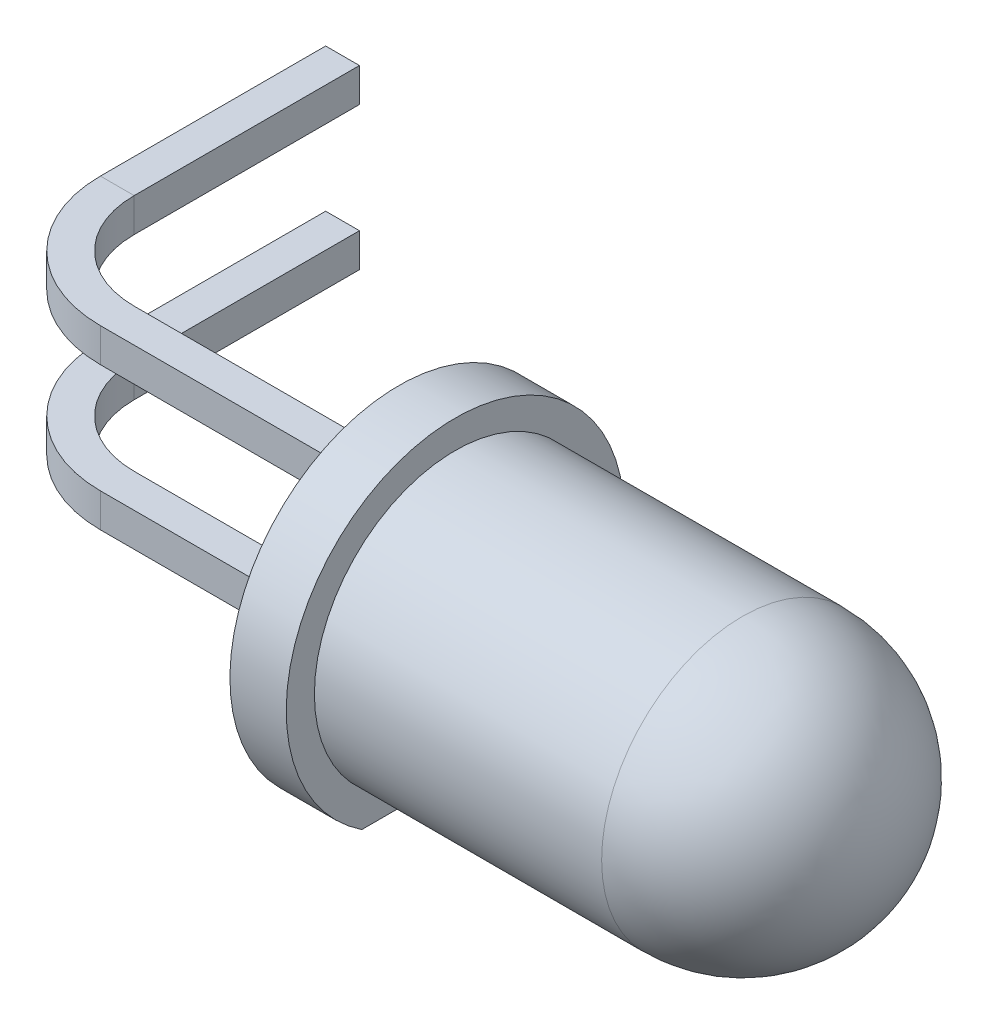
from build123d import *

# Parameters (mm, degrees)
ESQUISSE2_W             = 4.921723832
ESQUISSE2_H             = 0.78450296
ENL_V_MAT_EXTRU_1_DEPTH = 9.6
ESQUISSE3_W             = 0.6
ESQUISSE3_H             = 0.6
BOSS_EXTRU_2_DEPTH      = 5
BOSS_EXTRU_2_DEPTH_BACK = 5
BOSS_EXTRU_3_DEPTH      = 0.6
BOSS_EXTRU_4_DEPTH      = 0.6
ESQUISSE5_W             = 0.6
ESQUISSE5_H             = 0.6


with BuildPart() as part:
    # Esquisse1 → Révolution1 (revolve)
    with BuildSketch(Plane.XY, mode=Mode.PRIVATE) as r_volution1_sk:
        with BuildLine():
            Line((0, 0), (0, 3))
            Line((0, 3), (1, 3))
            Line((1, 3), (1, 2.5))
            Line((1, 2.5), (6.1, 2.5))
            ThreePointArc((6.1, 2.5), (7.867766953, 1.767766953), (8.6, 0))
            Line((8.6, 0), (8.55, 0))
            ThreePointArc((8.55, 0), (7.832411614, 1.732411614), (6.1, 2.45))
            Line((6.1, 2.45), (0.95, 2.45))
            Line((0.95, 2.45), (0.95, 2.95))
            Line((0.95, 2.95), (0.05, 2.95))
            Line((0.05, 2.95), (0.05, 0))
            Line((0.05, 0), (0, 0))
        make_face()
    revolve(r_volution1_sk.sketch.rotate(Axis((-3.652103808, 0, 0), (1, 0, 0)), 90), axis=Axis((-3.652103808, 0, 0), (1, 0, 0)))  # turned: the seam where the file's is

    # Esquisse2 → Enlèv. mat.-Extru.1 (cut, through all)
    with BuildSketch(Plane.ZY):
        with Locations((0.14038474, -2.89225148)):
            Rectangle(ESQUISSE2_W, ESQUISSE2_H)
    extrude(amount=-ENL_V_MAT_EXTRU_1_DEPTH, mode=Mode.SUBTRACT)

    # Esquisse3 → Boss.-Extru.2 (add, two sides)
    with BuildSketch(Plane.ZY) as boss_extru_2_sk:
        with Locations((0, -1.27)):
            Rectangle(ESQUISSE3_W, ESQUISSE3_H)
        with Locations((0, 1.27)):
            Rectangle(ESQUISSE3_W, ESQUISSE3_H)
    extrude(amount=BOSS_EXTRU_2_DEPTH)
    extrude(boss_extru_2_sk.sketch, amount=-BOSS_EXTRU_2_DEPTH_BACK)

    # Esquisse6 → Boss.-Extru.3 (add)
    with BuildSketch(Plane.XY.offset(0.3)):
        Polygon((5, 0.27), (5, -1.57), (3, -1.57), (3, -0.57), (4.5, 0.27), align=None)
    extrude(amount=-BOSS_EXTRU_3_DEPTH)

    # Esquisse7 → Boss.-Extru.4 (add)
    with BuildSketch(Plane.XY.offset(0.3)):
        Polygon((4.5, 0.974748074), (3, 0.134707712), (3, 0.974748074), align=None)
    extrude(amount=-BOSS_EXTRU_4_DEPTH)

    # Balayage4: sweep along a path in Esquisse4
    with BuildLine(Plane(origin=(0, -1.27, 0), x_dir=(1, 0, 0), z_dir=(0, 1, 0))) as balayage4_path:
        Line((-7, 6), (-7, 2))
        ThreePointArc((-7, 2), (-6.414213562, 0.585786438), (-5, 0))
    # Esquisse5 → Balayage4 (sweep)
    with BuildSketch(Plane.ZY.offset(5)):
        with Locations((0, -1.27)):
            Rectangle(ESQUISSE5_W, ESQUISSE5_H)
        with Locations((0, 1.27)):
            Rectangle(ESQUISSE5_W, ESQUISSE5_H)
    sweep(path=balayage4_path.line)


solid = part.part
